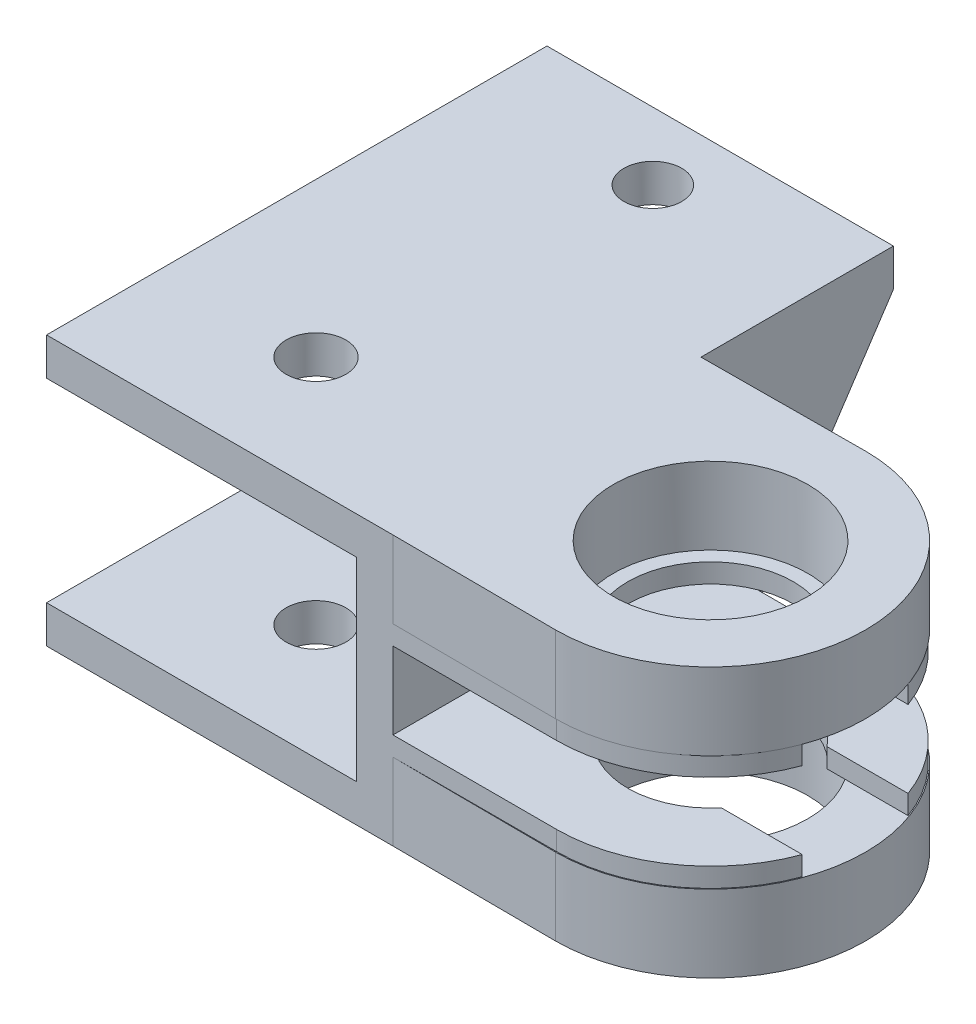
from build123d import *

# Parameters (mm, degrees)
SKETCH1_W           = 18
SKETCH1_H           = 16
BOSS_EXTRUDE1_DEPTH = 7
SKETCH4_W           = 16
SKETCH4_H           = 10.1
CUT_EXTRUDE1_DEPTH  = 16.1
SKETCH5_R           = 5.05
BOSS_EXTRUDE2_DEPTH = 4
SKETCH7_W           = 18
SKETCH7_H           = 1.95
BOSS_EXTRUDE3_DEPTH = 10
SKETCH8_R           = 1.5
CUT_EXTRUDE2_DEPTH  = 1.95
BOSS_EXTRUDE4_DEPTH = 1
SKETCH10_R          = 1.55
CUT_EXTRUDE3_DEPTH  = 14
SKETCH13_W          = 18
SKETCH13_H          = 12.05
BOSS_EXTRUDE6_DEPTH = 2
BOSS_EXTRUDE7_DEPTH = 2
SKETCH15_W          = 16.1
SKETCH15_H          = 10.1
CUT_EXTRUDE4_DEPTH  = 0.1


with BuildPart() as part:
    # Sketch1 → Boss-Extrude1 (new body, symmetric)
    with BuildSketch(Plane(origin=(0, 0, 0), x_dir=(1, 0, 0), z_dir=(0, 1, 0))):
        with Locations((-9, 0)):
            Rectangle(SKETCH1_W, SKETCH1_H)
    extrude(amount=BOSS_EXTRUDE1_DEPTH, both=True)

    # Sketch4 → Cut-Extrude1 (cut)
    with BuildSketch(Plane.ZY.offset(18)):
        Rectangle(SKETCH4_W, SKETCH4_H)
    extrude(amount=-CUT_EXTRUDE1_DEPTH, mode=Mode.SUBTRACT)

    # Sketch5 → Boss-Extrude2 (add)
    with BuildSketch(Plane.XZ.offset(7)):
        with BuildLine():
            Line((0, 8), (8.5, 8.05))
            ThreePointArc((8.5, 8.05), (16.55, 0), (8.5, -8.05))
            Line((8.5, -8.05), (0, -8))
            Line((0, -8), (0, 8))
        make_face()
        with Locations((8.5, 0)):
            Circle(SKETCH5_R, mode=Mode.SUBTRACT)
    boss_extrude2 = extrude(amount=-BOSS_EXTRUDE2_DEPTH)

    # Mirror1: Boss-Extrude2 across plane
    add(boss_extrude2.mirror(Plane(origin=(0, 0, 0), x_dir=(0, 0, 1), z_dir=(0, -1, 0))))

    # Sketch7 → Boss-Extrude3 (add)
    with BuildSketch(Plane(origin=(0, 0, -8), x_dir=(-1, 0, 0), z_dir=(0, 0, -1))):
        with Locations((9, 6.025)):
            Rectangle(SKETCH7_W, SKETCH7_H)
    extrude(amount=BOSS_EXTRUDE3_DEPTH)

    # Sketch8 → Cut-Extrude2 (cut)
    with BuildSketch(Plane.XZ.offset(-7)):
        with Locations((-9, -14.5)):
            Circle(SKETCH8_R)
    extrude(amount=CUT_EXTRUDE2_DEPTH, mode=Mode.SUBTRACT)

    # Sketch9 → Boss-Extrude4 (add)
    with BuildSketch(Plane(origin=(0, -3, 0), x_dir=(1, 0, 0), z_dir=(0, 1, 0))):
        with BuildLine():
            Line((11.805676935, -2.75), (16.012489601, -2.75))
            ThreePointArc((16.012489601, -2.75), (13.082575695, -6.557438524), (8.5, -8))
            Line((8.5, -8), (0, -8))
            Line((0, -8), (0, 8))
            Line((0, 8), (8.5, 8))
            ThreePointArc((8.5, 8), (13.082575695, 6.557438524), (16.012489601, 2.75))
            Line((16.012489601, 2.75), (11.805676935, 2.75))
            ThreePointArc((11.805676935, 2.75), (4.2, 0), (11.805676935, -2.75))
        make_face()
    boss_extrude4 = extrude(amount=BOSS_EXTRUDE4_DEPTH)

    # Mirror2: Boss-Extrude4 across plane
    add(boss_extrude4.mirror(Plane(origin=(0, 0, 0), x_dir=(0, 0, 1), z_dir=(0, -1, 0))))

    # Sketch10 → Cut-Extrude3 (cut)
    with BuildSketch(Plane.XZ.offset(7)):
        with Locations((-10, 2)):
            Circle(SKETCH10_R)
    extrude(amount=-CUT_EXTRUDE3_DEPTH, mode=Mode.SUBTRACT)

    # Sketch13 → Boss-Extrude6 (add)
    with BuildSketch(Plane(origin=(0, 0, -8), x_dir=(-1, 0, 0), z_dir=(0, 0, -1))):
        with Locations((9, -0.975)):
            Rectangle(SKETCH13_W, SKETCH13_H)
    extrude(amount=BOSS_EXTRUDE6_DEPTH)

    # Sketch14 → Boss-Extrude7 (add)
    with BuildSketch(Plane(origin=(0, 0, 0), x_dir=(0, 0, -1), z_dir=(1, 0, 0))):
        Polygon((10, -7), (18, 5.05), (10, 5.05), align=None)
    boss_extrude7 = extrude(amount=-BOSS_EXTRUDE7_DEPTH)

    # Mirror3: Boss-Extrude7 across plane
    add(boss_extrude7.mirror(Plane(origin=(-9, 0, 0), x_dir=(0, 0, 1), z_dir=(1, 0, 0))))

    # Sketch15 → Cut-Extrude4 (cut)
    with BuildSketch(Plane.XY.offset(-8)):
        with Locations((-9.95, 0)):
            Rectangle(SKETCH15_W, SKETCH15_H)
    extrude(amount=-CUT_EXTRUDE4_DEPTH, mode=Mode.SUBTRACT)


solid = part.part
